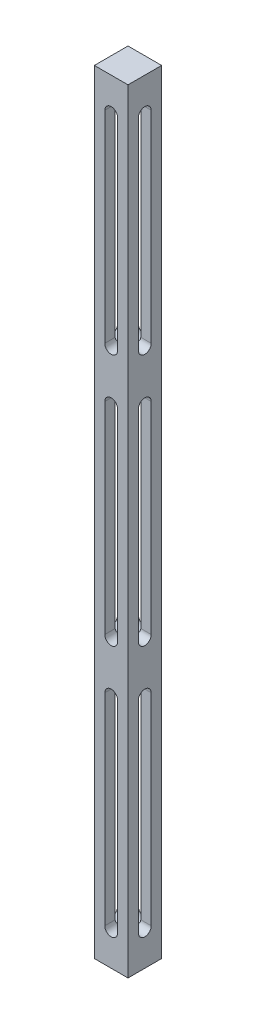
from build123d import *

# Parameters (mm, degrees)
SKETCH1_W           = 12.7
SKETCH1_H           = 12.7
BOSS_EXTRUDE1_DEPTH = 292.1
CUT_EXTRUDE1_DEPTH  = 13.7
CUT_EXTRUDE2_DEPTH  = 13.7
LPATTERN1_COUNT     = 3
LPATTERN1_PITCH     = 95.25


with BuildPart() as part:
    # Sketch1 → Boss-Extrude1 (new body)
    with BuildSketch(Plane(origin=(0, 0, 0), x_dir=(1, 0, 0), z_dir=(0, 1, 0))):
        Rectangle(SKETCH1_W, SKETCH1_H)
    extrude(amount=BOSS_EXTRUDE1_DEPTH)

    # Sketch2 → Cut-Extrude1 (cut, through all)
    with BuildSketch(Plane(origin=(0, 0, -6.35), x_dir=(-1, 0, 0), z_dir=(0, 0, -1))):
        with BuildLine():
            Line((-2.413, 279.4), (-2.413, 203.2))
            ThreePointArc((-2.413, 203.2), (0, 200.787), (2.413, 203.2))
            Line((2.413, 203.2), (2.413, 279.4))
            ThreePointArc((2.413, 279.4), (0, 281.813), (-2.413, 279.4))
        make_face()
    cut_extrude1 = extrude(amount=-CUT_EXTRUDE1_DEPTH, mode=Mode.SUBTRACT)

    # Sketch3 → Cut-Extrude2 (cut, through all)
    with BuildSketch(Plane(origin=(6.35, 0, 0), x_dir=(0, 0, -1), z_dir=(1, 0, 0))):
        with BuildLine():
            Line((-2.413, 279.4), (-2.413, 203.2))
            ThreePointArc((-2.413, 203.2), (0, 200.787), (2.413, 203.2))
            Line((2.413, 203.2), (2.413, 279.4))
            ThreePointArc((2.413, 279.4), (0, 281.813), (-2.413, 279.4))
        make_face()
    cut_extrude2 = extrude(amount=-CUT_EXTRUDE2_DEPTH, mode=Mode.SUBTRACT)

    # LPattern1: Cut-Extrude1, Cut-Extrude2 ×3
    with Locations(*[(0, -i * LPATTERN1_PITCH, 0) for i in range(1, LPATTERN1_COUNT)]):
        add(cut_extrude1, mode=Mode.SUBTRACT)
        add(cut_extrude2, mode=Mode.SUBTRACT)


solid = part.part
